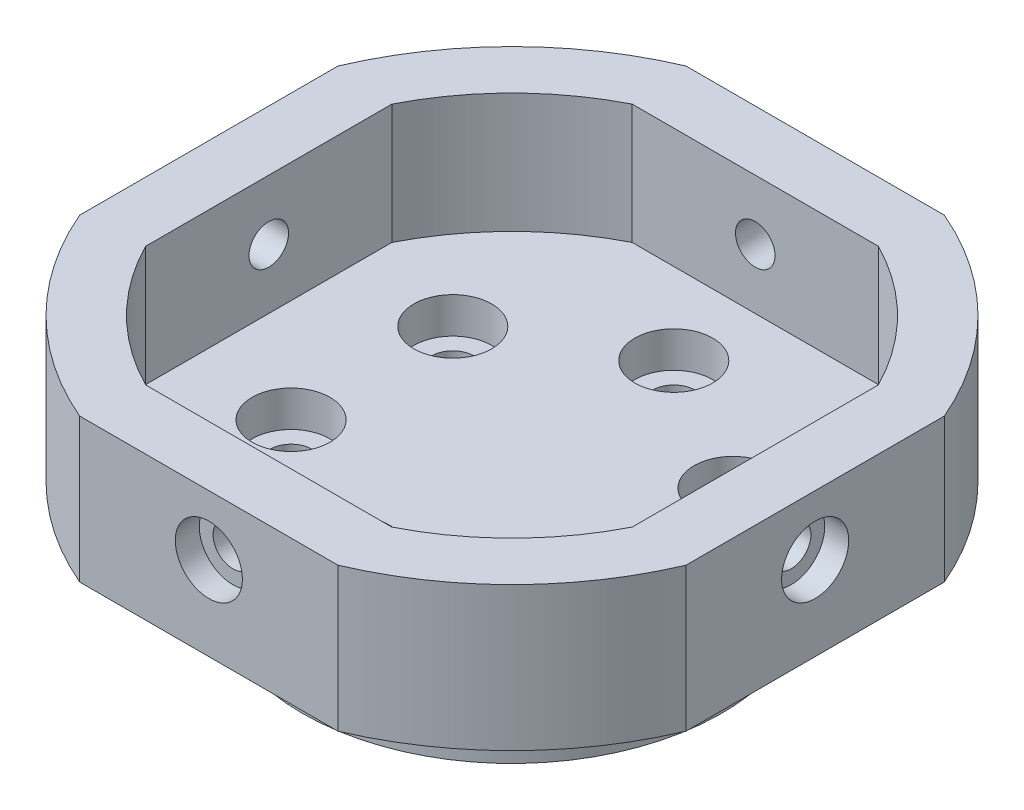
from build123d import *

# Parameters (mm, degrees)
SKETCH_1_R           = 17.5
SKETCH_1_R_2         = 1.75
EXTRUDE_1_DEPTH      = 10
SKETCH_2_R           = 25
SKETCH_2_R_2         = 17.5
EXTRUDE_2_DEPTH      = 2
SKETCH_3_R           = 3.25
CUT_EXTRUDE_1_DEPTH  = 3
EXTRUDE_3_DEPTH      = 10
EXTRUDE_3_DEPTH_BACK = 2
SKETCH_6_R           = 1.65
CUT_EXTRUDE_2_DEPTH  = 54.5
SKETCH_7_R           = 1.65
CUT_EXTRUDE_3_DEPTH  = 54.5
SKETCH_8_R           = 2.8
CUT_EXTRUDE_4_DEPTH  = 2
SKETCH_9_R           = 2.8
CUT_EXTRUDE_5_DEPTH  = 2
SKETCH_10_R          = 2.8
CUT_EXTRUDE_6_DEPTH  = 2
SKETCH_11_R          = 2.8
CUT_EXTRUDE_7_DEPTH  = 2


with BuildPart() as part:
    # 草图1 → 凸台-拉伸1 (new body)
    with BuildSketch(Plane(origin=(0, 0, 0), x_dir=(1, 0, 0), z_dir=(0, 1, 0))):
        Circle(SKETCH_1_R)
        with Locations((0, 13.5)):
            Circle(SKETCH_1_R_2, mode=Mode.SUBTRACT)
        with Locations((11.691342951, 6.75)):
            Circle(SKETCH_1_R_2, mode=Mode.SUBTRACT)
        with Locations((11.691342951, -6.75)):
            Circle(SKETCH_1_R_2, mode=Mode.SUBTRACT)
        with Locations((0, -13.5)):
            Circle(SKETCH_1_R_2, mode=Mode.SUBTRACT)
        with Locations((-11.691342951, -6.75)):
            Circle(SKETCH_1_R_2, mode=Mode.SUBTRACT)
        with Locations((-11.691342951, 6.75)):
            Circle(SKETCH_1_R_2, mode=Mode.SUBTRACT)
    extrude(amount=EXTRUDE_1_DEPTH)

    # 草图2 → 凸台-拉伸2 (add)
    with BuildSketch(Plane(origin=(0, 10, 0), x_dir=(1, 0, 0), z_dir=(0, 1, 0))):
        Circle(SKETCH_2_R)
        Circle(SKETCH_2_R_2, mode=Mode.SUBTRACT)
    extrude(amount=-EXTRUDE_2_DEPTH)

    # 草图3 → 切除-拉伸1 (cut)
    with BuildSketch(Plane(origin=(0, 10, 0), x_dir=(1, 0, 0), z_dir=(0, 1, 0))):
        with Locations((0, 13.5)):
            Circle(SKETCH_3_R)
        with Locations((11.691342951, 6.75)):
            Circle(SKETCH_3_R)
        with Locations((11.691342951, -6.75)):
            Circle(SKETCH_3_R)
        with Locations((0, -13.5)):
            Circle(SKETCH_3_R)
        with Locations((-11.691342951, -6.75)):
            Circle(SKETCH_3_R)
        with Locations((-11.691342951, 6.75)):
            Circle(SKETCH_3_R)
    extrude(amount=-CUT_EXTRUDE_1_DEPTH, mode=Mode.SUBTRACT)

    # 草图4 → 凸台-拉伸3 (add, two sides)
    with BuildSketch(Plane(origin=(0, 10, 0), x_dir=(1, 0, 0), z_dir=(0, 1, 0))) as extrude_3_sk:
        with BuildLine():
            Line((-10.777754868, 25.3), (10.777754868, 25.3))
            ThreePointArc((10.777754868, 25.3), (19.445436483, 19.445436483), (25.3, 10.777754868))
            Line((25.3, 10.777754868), (25.3, -10.777754868))
            ThreePointArc((25.3, -10.777754868), (19.445436483, -19.445436483), (10.777754868, -25.3))
            Line((10.777754868, -25.3), (-10.777754868, -25.3))
            ThreePointArc((-10.777754868, -25.3), (-19.445436483, -19.445436483), (-25.3, -10.777754868))
            Line((-25.3, -10.777754868), (-25.3, 10.777754868))
            ThreePointArc((-25.3, 10.777754868), (-19.445436483, 19.445436483), (-10.777754868, 25.3))
        make_face()
        with BuildLine():
            Line((-10.269980526, 20.3), (10.269980526, 20.3))
            ThreePointArc((10.269980526, 20.3), (16.086679272, 16.086679272), (20.3, 10.269980526))
            Line((20.3, 10.269980526), (20.3, -10.269980526))
            ThreePointArc((20.3, -10.269980526), (16.086679272, -16.086679272), (10.269980526, -20.3))
            Line((10.269980526, -20.3), (-10.269980526, -20.3))
            ThreePointArc((-10.269980526, -20.3), (-16.086679272, -16.086679272), (-20.3, -10.269980526))
            Line((-20.3, -10.269980526), (-20.3, 10.269980526))
            ThreePointArc((-20.3, 10.269980526), (-16.086679272, 16.086679272), (-10.269980526, 20.3))
        make_face(mode=Mode.SUBTRACT)
    extrude(amount=EXTRUDE_3_DEPTH)
    extrude(extrude_3_sk.sketch, amount=-EXTRUDE_3_DEPTH_BACK)

    # 草图6 → 切除-拉伸2 (cut, symmetric)
    with BuildSketch(Plane.XY.offset(25.3)):
        with Locations((0, 15)):
            Circle(SKETCH_6_R)
    extrude(amount=CUT_EXTRUDE_2_DEPTH, both=True, mode=Mode.SUBTRACT)

    # 草图7 → 切除-拉伸3 (cut, symmetric)
    with BuildSketch(Plane(origin=(25.3, 0, 0), x_dir=(0, 0, -1), z_dir=(1, 0, 0))):
        with Locations((0, 15)):
            Circle(SKETCH_7_R)
    extrude(amount=CUT_EXTRUDE_3_DEPTH, both=True, mode=Mode.SUBTRACT)

    # 草图8 → 切除-拉伸4 (cut)
    with BuildSketch(Plane(origin=(25.3, 0, 0), x_dir=(0, 0, -1), z_dir=(1, 0, 0))):
        with Locations((0, 15)):
            Circle(SKETCH_8_R)
    extrude(amount=-CUT_EXTRUDE_4_DEPTH, mode=Mode.SUBTRACT)

    # 草图9 → 切除-拉伸5 (cut)
    with BuildSketch(Plane(origin=(0, 0, -25.3), x_dir=(-1, 0, 0), z_dir=(0, 0, -1))):
        with Locations((0, 15)):
            Circle(SKETCH_9_R)
    extrude(amount=-CUT_EXTRUDE_5_DEPTH, mode=Mode.SUBTRACT)

    # 草图10 → 切除-拉伸6 (cut)
    with BuildSketch(Plane.ZY.offset(25.3)):
        with Locations((0, 15)):
            Circle(SKETCH_10_R)
    extrude(amount=-CUT_EXTRUDE_6_DEPTH, mode=Mode.SUBTRACT)

    # 草图11 → 切除-拉伸7 (cut)
    with BuildSketch(Plane.XY.offset(25.3)):
        with Locations((0, 15)):
            Circle(SKETCH_11_R)
    extrude(amount=-CUT_EXTRUDE_7_DEPTH, mode=Mode.SUBTRACT)


solid = part.part
